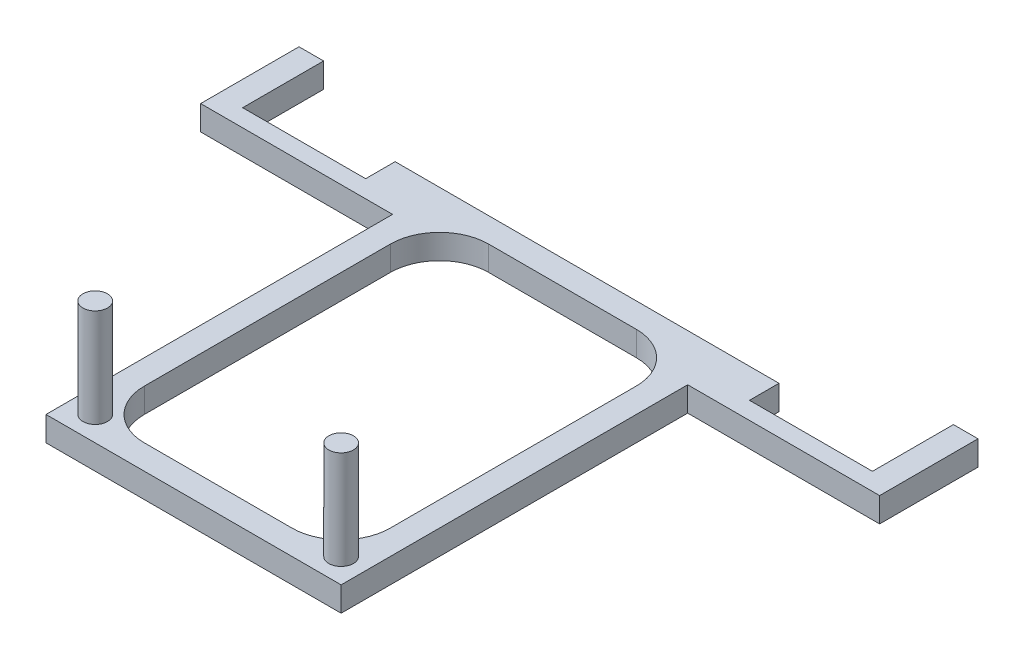
from build123d import *

# Parameters (mm, degrees)
BOSS_EXTRUDE2_DEPTH     = 1.27
SKETCH3_R               = 0.635
BOSS_EXTRUDE3_DEPTH     = 6.35
CUT_EXTRUDE1_DEPTH      = 6.35
CUT_EXTRUDE1_DEPTH_BACK = 6.35


with BuildPart() as part:
    # Sketch1 → Boss-Extrude2 (new body)
    with BuildSketch(Plane(origin=(0, 0, 0), x_dir=(1, 0, 0), z_dir=(0, 1, 0))):
        Polygon((7.62, -10.16), (-7.62, -10.16), (-7.62, 7.736503278), (-17.531075881, 7.736503278), (-17.531075881, 10.276503278), (-17.531075881, 12.816503278), (-16.261075881, 12.816503278), (-16.261075881, 10.16), (-16.261075881, 8.636), (-9.911075881, 8.636), (-9.911075881, 10.16), (-7.62, 10.16), (7.62, 10.16), (9.911075881, 10.16), (9.911075881, 8.636), (16.261075881, 8.636), (16.261075881, 10.16), (16.261075881, 12.816503278), (17.531075881, 12.816503278), (17.531075881, 10.276503278), (17.531075881, 7.736503278), (7.62, 7.736503278), align=None)
    extrude(amount=BOSS_EXTRUDE2_DEPTH)

    # Sketch3 → Boss-Extrude3 (add)
    with BuildSketch(Plane(origin=(0, 0, 0), x_dir=(1, 0, 0), z_dir=(0, 1, 0))):
        with Locations((-6.35, -8.89)):
            Circle(SKETCH3_R)
        with Locations((6.35, -8.89)):
            Circle(SKETCH3_R)
    extrude(amount=BOSS_EXTRUDE3_DEPTH)

    # Sketch4 → Cut-Extrude1 (cut, two sides)
    with BuildSketch(Plane(origin=(0, 0, 0), x_dir=(1, 0, 0), z_dir=(0, 1, 0))) as cut_extrude1_sk:
        with BuildLine():
            Line((3.81, -8.89), (-3.81, -8.89))
            ThreePointArc((-3.81, -8.89), (-5.606051224, -8.146051224), (-6.35, -6.35))
            Line((-6.35, -6.35), (-6.35, 6.35))
            ThreePointArc((-6.35, 6.35), (-5.606051224, 8.146051224), (-3.81, 8.89))
            Line((-3.81, 8.89), (3.81, 8.89))
            ThreePointArc((3.81, 8.89), (5.606051224, 8.146051224), (6.35, 6.35))
            Line((6.35, 6.35), (6.35, -6.35))
            ThreePointArc((6.35, -6.35), (5.606051224, -8.146051224), (3.81, -8.89))
        make_face()
    extrude(amount=CUT_EXTRUDE1_DEPTH, mode=Mode.SUBTRACT)
    extrude(cut_extrude1_sk.sketch, amount=-CUT_EXTRUDE1_DEPTH_BACK, mode=Mode.SUBTRACT)


solid = part.part
